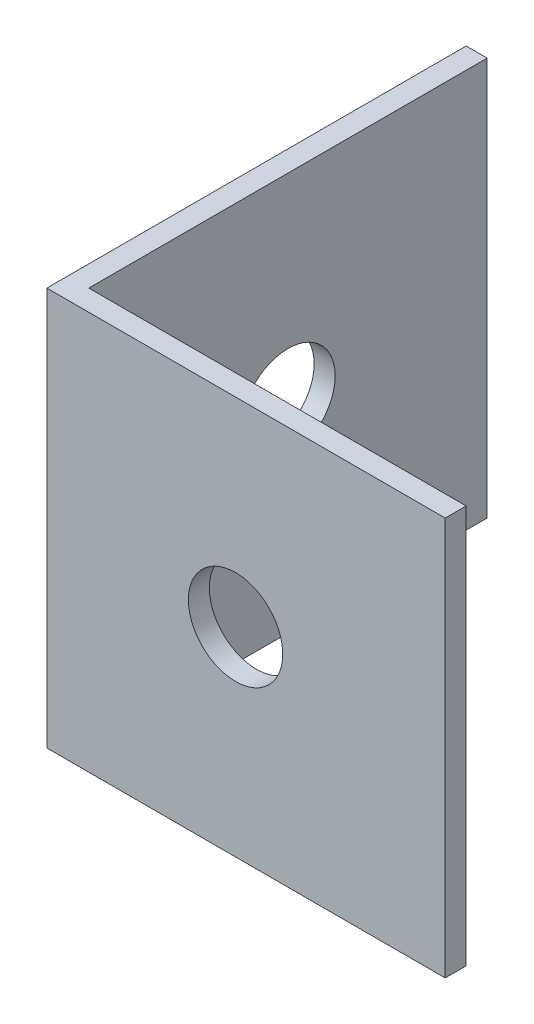
from build123d import *

# Parameters (mm, degrees)
EXTRUDE_1_DEPTH     = 19
SKETCH_3_W          = 1
SKETCH_3_H          = 19
CUT_EXTRUDE_1_DEPTH = 1
SKETCH_4_R          = 2.25
CUT_EXTRUDE_2_DEPTH = 2
SKETCH_5_R          = 2.25
CUT_EXTRUDE_3_DEPTH = 2


with BuildPart() as part:
    # Эскиз1 → Бобышка-Вытянуть1 (new body)
    with BuildSketch(Plane(origin=(0, 0, 0), x_dir=(1, 0, 0), z_dir=(0, 1, 0))):
        Polygon((0, 0), (0, 20), (1, 20), (1, 1), (20, 1), (20, 0), align=None)
    extrude(amount=EXTRUDE_1_DEPTH)

    # Эскиз3 → Вырез-Вытянуть1 (cut)
    with BuildSketch(Plane(origin=(20, 0, 0), x_dir=(0, 0, -1), z_dir=(1, 0, 0))):
        with Locations((0.5, 9.5)):
            Rectangle(SKETCH_3_W, SKETCH_3_H)
    extrude(amount=-CUT_EXTRUDE_1_DEPTH, mode=Mode.SUBTRACT)

    # Эскиз4 → Вырез-Вытянуть2 (cut, through all)
    with BuildSketch(Plane(origin=(1, 0, 0), x_dir=(0, 0, -1), z_dir=(1, 0, 0))):
        with Locations((10.5, 9.5)):
            Circle(SKETCH_4_R)
    extrude(amount=-CUT_EXTRUDE_2_DEPTH, mode=Mode.SUBTRACT)

    # Эскиз5 → Вырез-Вытянуть3 (cut, through all)
    with BuildSketch(Plane(origin=(0, 0, -1), x_dir=(-1, 0, 0), z_dir=(0, 0, -1))):
        with Locations((-9, 9.5)):
            Circle(SKETCH_5_R)
    extrude(amount=-CUT_EXTRUDE_3_DEPTH, mode=Mode.SUBTRACT)


solid = part.part
